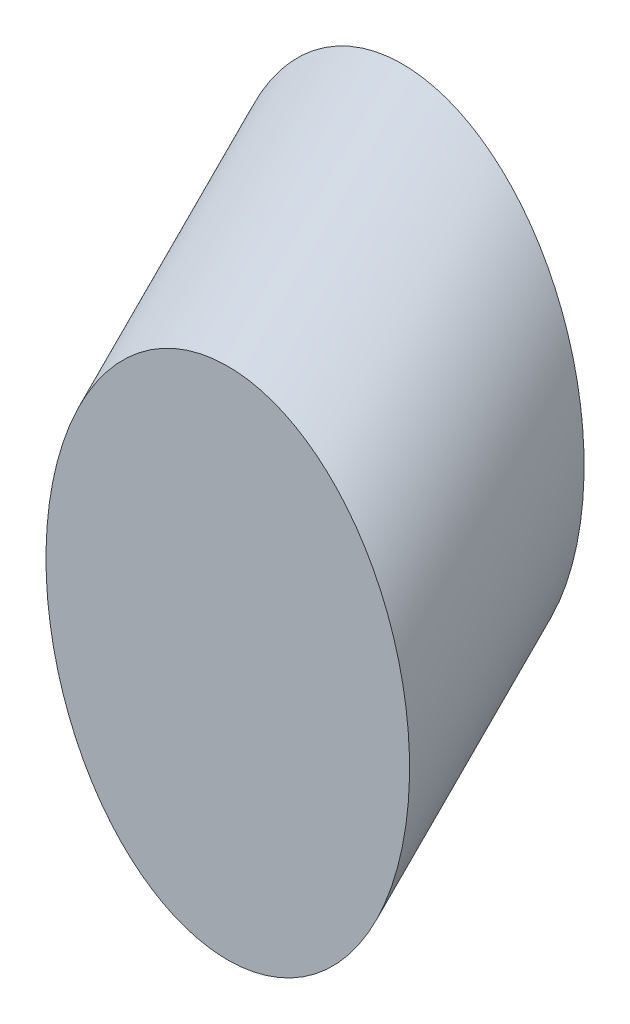
from build123d import *

# Parameters (mm, degrees)
SKETCH_1_RX     = 8.84
SKETCH_1_RY     = 6.25
EXTRUDE_2_DEPTH = 8.4853


with BuildPart() as part:
    # 草图1 → 凸台-拉伸2 (new body, along a direction that is not the sketch's normal)
    with BuildSketch(Plane.XY):
        with Locations(Location((54.392382982, 35.78887153), (0, 0, -90))):
            Ellipse(SKETCH_1_RX, SKETCH_1_RY)
    extrude(amount=-EXTRUDE_2_DEPTH, dir=(0, -0.707106781, 0.707106781))


solid = part.part
